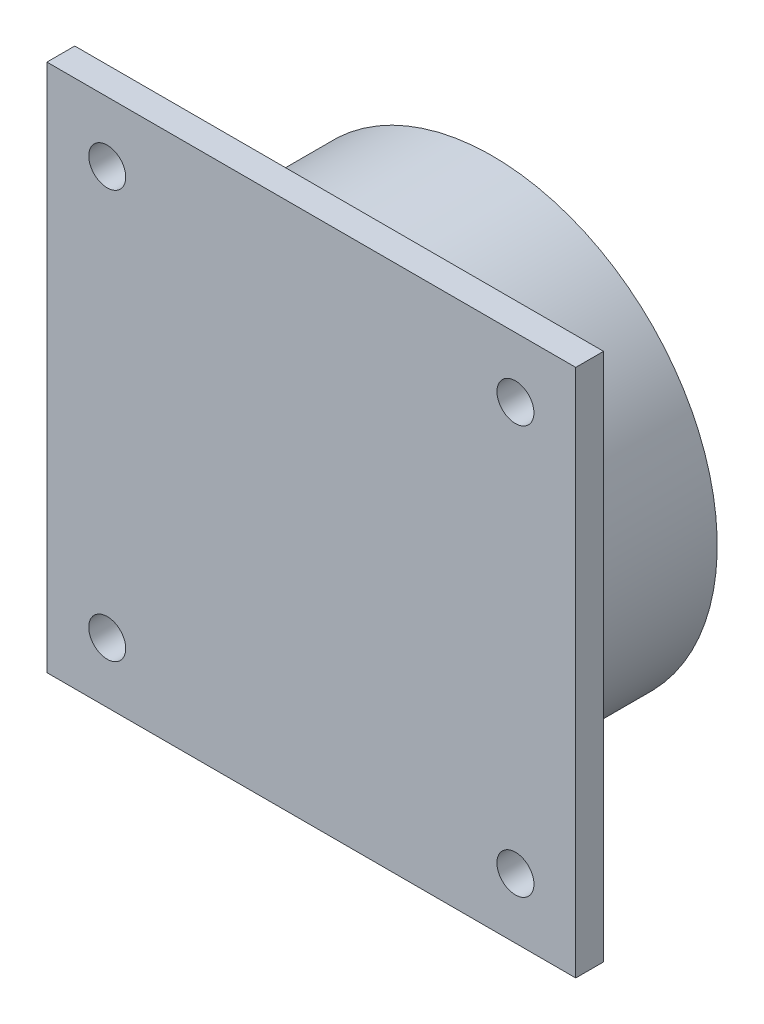
from build123d import *

# Parameters (mm, degrees)
SKETCH2_W           = 57
SKETCH2_H           = 57
BOSS_EXTRUDE1_DEPTH = 3
SKETCH3_R           = 24.25
BOSS_EXTRUDE2_DEPTH = 16.5
SKETCH4_R           = 1.9939
CUT_EXTRUDE1_DEPTH  = 16.5


with BuildPart() as part:
    # Sketch2 → Boss-Extrude1 (new body)
    with BuildSketch(Plane.XY):
        with Locations((14.592, 4.446)):
            Rectangle(SKETCH2_W, SKETCH2_H)
    extrude(amount=BOSS_EXTRUDE1_DEPTH)

    # Sketch3 → Boss-Extrude2 (add)
    with BuildSketch(Plane(origin=(0, 0, 0), x_dir=(-1, 0, 0), z_dir=(0, 0, -1))):
        with Locations((-14.592, 4.446)):
            Circle(SKETCH3_R)
    extrude(amount=BOSS_EXTRUDE2_DEPTH)

    # Sketch4 → Cut-Extrude1 (cut)
    with BuildSketch(Plane.XY.offset(3)):
        with Locations((36.592, 26.446)):
            Circle(SKETCH4_R)
        with Locations((36.592, -17.554)):
            Circle(SKETCH4_R)
        with Locations((-7.408, -17.554)):
            Circle(SKETCH4_R)
        with Locations((-7.408, 26.446)):
            Circle(SKETCH4_R)
    extrude(amount=-CUT_EXTRUDE1_DEPTH, mode=Mode.SUBTRACT)


solid = part.part
